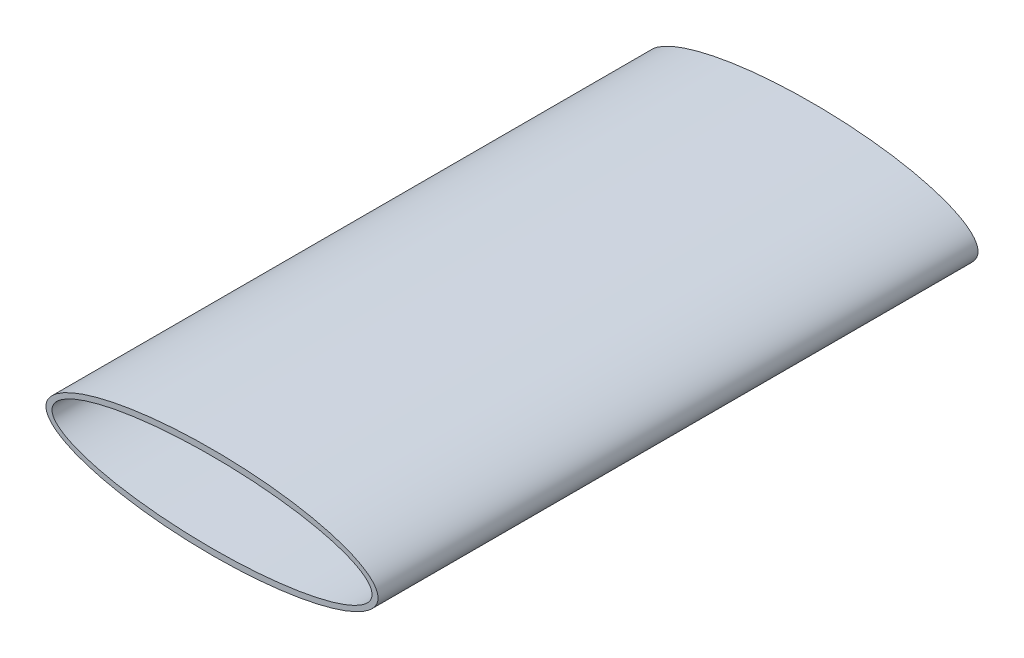
from build123d import *

# Parameters (mm, degrees)
SKETCH_1_RX     = 830
SKETCH_1_RY     = 230
SKETCH_1_RX_2   = 800
SKETCH_1_RY_2   = 200
EXTRUDE_1_DEPTH = 3000


with BuildPart() as part:
    # Эскиз1 → Вытянуть1 (new body)
    with BuildSketch(Plane.XY):
        with Locations(Location((1000, 400), (0, 0, 180))):
            Ellipse(SKETCH_1_RX, SKETCH_1_RY)
        with Locations(Location((1000, 400), (0, 0, 180))):
            Ellipse(SKETCH_1_RX_2, SKETCH_1_RY_2, mode=Mode.SUBTRACT)
    extrude(amount=-EXTRUDE_1_DEPTH)


solid = part.part
